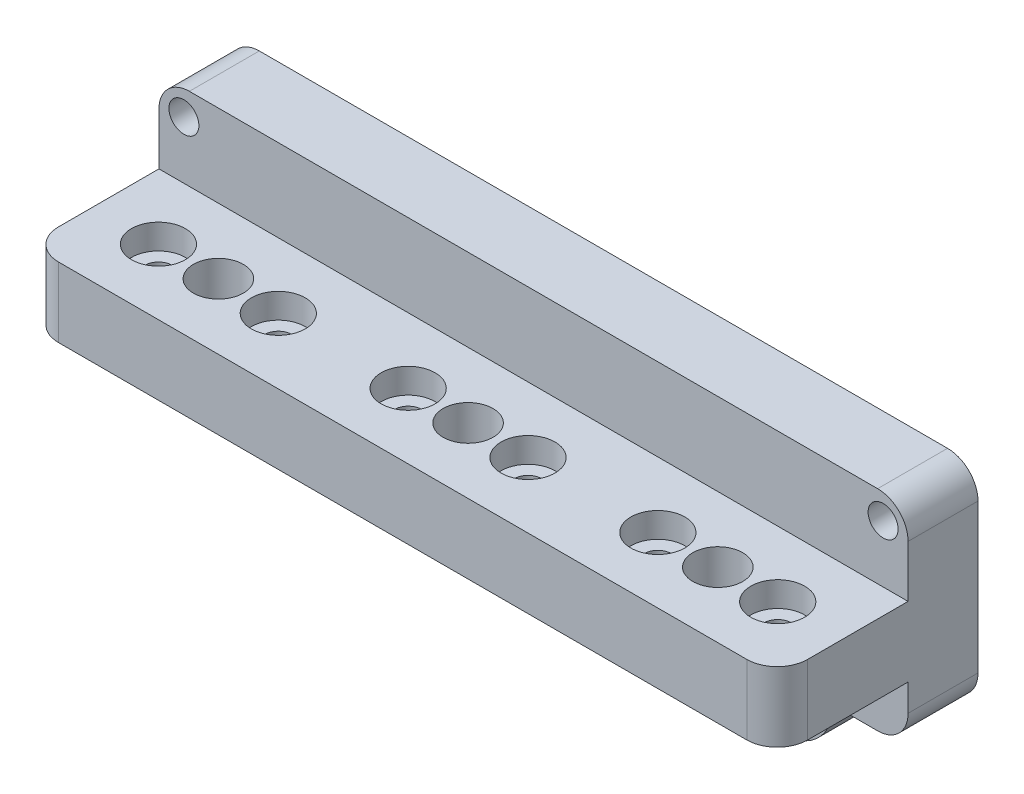
from build123d import *

# Parameters (mm, degrees)
SKETCH1_R           = 1.79994
SKETCH1_R_2         = 1.5
BOSS_EXTRUDE1_DEPTH = 7
SKETCH2_W           = 75
SKETCH2_H           = 13.099999962
SKETCH2_R           = 2.6999438
SKETCH2_R_2         = 2.499995
SKETCH2_R_3         = 1.3498449
BOSS_EXTRUDE2_DEPTH = 6.987999994
SKETCH2_3_R         = 2.6999438
SKETCH2_3_R_2       = 1.3498449
CUT_EXTRUDE1_DEPTH  = 2.5
SKETCH7_W           = 45.754771374
SKETCH7_H           = 7.378762064
SKETCH7_W_2         = 5.75825354
SKETCH7_H_2         = 4.98011117
BOSS_EXTRUDE4_DEPTH = 7
SKETCH8_W           = 15.938133918
SKETCH8_H           = 10.613167284
CUT_EXTRUDE3_DEPTH  = 21.288
FILLET3_R           = 3.048
SKETCH4_W           = 25
SKETCH4_H           = 15.064836289
CUT_EXTRUDE2_DEPTH  = 38.822


with BuildPart() as part:
    # Sketch1 → Boss-Extrude1 (new body)
    with BuildSketch(Plane.XY):
        with BuildLine():
            Line((37.5, -10.5), (30, -10.5))
            ThreePointArc((30, -10.5), (25, -15.5), (20, -10.5))
            Line((20, -10.5), (5, -10.5))
            ThreePointArc((5, -10.5), (0, -15.5), (-5, -10.5))
            Line((-5, -10.5), (-20, -10.5))
            ThreePointArc((-20, -10.5), (-25, -15.5), (-30, -10.5))
            Line((-30, -10.5), (-37.5, -10.5))
            Line((-37.5, -10.5), (-37.5, 10.5))
            Line((-37.5, 10.5), (37.5, 10.5))
            Line((37.5, 10.5), (37.5, -10.5))
        make_face()
        with Locations((-25, -10.5)):
            Circle(SKETCH1_R, mode=Mode.SUBTRACT)
        with Locations((0, -10.5)):
            Circle(SKETCH1_R, mode=Mode.SUBTRACT)
        with Locations((25, -10.5)):
            Circle(SKETCH1_R, mode=Mode.SUBTRACT)
        with Locations((-35, 8)):
            Circle(SKETCH1_R_2, mode=Mode.SUBTRACT)
        with Locations((-15, 8)):
            Circle(SKETCH1_R_2, mode=Mode.SUBTRACT)
        with Locations((-10, 8)):
            Circle(SKETCH1_R_2, mode=Mode.SUBTRACT)
        with Locations((10, 8)):
            Circle(SKETCH1_R_2, mode=Mode.SUBTRACT)
        with Locations((35, 8)):
            Circle(SKETCH1_R_2, mode=Mode.SUBTRACT)
        with Locations((15, 8)):
            Circle(SKETCH1_R_2, mode=Mode.SUBTRACT)
    extrude(amount=BOSS_EXTRUDE1_DEPTH)

    # Sketch2 → Boss-Extrude2 (add)
    with BuildSketch(Plane(origin=(0, 2.24999999, 0), x_dir=(1, 0, 0), z_dir=(0, 1, 0))):
        with Locations((0, -13.549999981)):
            Rectangle(SKETCH2_W, SKETCH2_H)
        with Locations((31.0001404, -13.549999981)):
            Circle(SKETCH2_R, mode=Mode.SUBTRACT)
        with Locations((-31.0001404, -13.549999981)):
            Circle(SKETCH2_R, mode=Mode.SUBTRACT)
        with Locations((-25, -13.549999981)):
            Circle(SKETCH2_R_2, mode=Mode.SUBTRACT)
        with Locations((-6.0001404, -13.549999981)):
            Circle(SKETCH2_R, mode=Mode.SUBTRACT)
        with Locations((6.0001404, -13.549999981)):
            Circle(SKETCH2_R, mode=Mode.SUBTRACT)
        with Locations((0, -13.549999981)):
            Circle(SKETCH2_R_2, mode=Mode.SUBTRACT)
        with Locations((-18.9998596, -13.549999981)):
            Circle(SKETCH2_R, mode=Mode.SUBTRACT)
        with Locations((25, -13.549999981)):
            Circle(SKETCH2_R_2, mode=Mode.SUBTRACT)
        with Locations((18.9998596, -13.549999981)):
            Circle(SKETCH2_R, mode=Mode.SUBTRACT)
        with Locations((-31.0001404, -13.549999981)):
            Circle(SKETCH2_R)
        with Locations((-31.0001404, -13.549999981)):
            Circle(SKETCH2_R_3, mode=Mode.SUBTRACT)
        with Locations((-18.9998596, -13.549999981)):
            Circle(SKETCH2_R)
        with Locations((-18.9998596, -13.549999981)):
            Circle(SKETCH2_R_3, mode=Mode.SUBTRACT)
        with Locations((-6.0001404, -13.549999981)):
            Circle(SKETCH2_R)
        with Locations((-6.0001404, -13.549999981)):
            Circle(SKETCH2_R_3, mode=Mode.SUBTRACT)
        with Locations((6.0001404, -13.549999981)):
            Circle(SKETCH2_R)
        with Locations((6.0001404, -13.549999981)):
            Circle(SKETCH2_R_3, mode=Mode.SUBTRACT)
        with Locations((18.9998596, -13.549999981)):
            Circle(SKETCH2_R)
        with Locations((18.9998596, -13.549999981)):
            Circle(SKETCH2_R_3, mode=Mode.SUBTRACT)
        with Locations((31.0001404, -13.549999981)):
            Circle(SKETCH2_R)
        with Locations((31.0001404, -13.549999981)):
            Circle(SKETCH2_R_3, mode=Mode.SUBTRACT)
    extrude(amount=-BOSS_EXTRUDE2_DEPTH)

    # Sketch2_3 → Cut-Extrude1 (cut)
    with BuildSketch(Plane(origin=(0, 2.24999999, 0), x_dir=(1, 0, 0), z_dir=(0, 1, 0))):
        with Locations((-31.0001404, -13.549999981)):
            Circle(SKETCH2_3_R)
        with Locations((-31.0001404, -13.549999981)):
            Circle(SKETCH2_3_R_2, mode=Mode.SUBTRACT)
        with Locations((-18.9998596, -13.549999981)):
            Circle(SKETCH2_3_R)
        with Locations((-18.9998596, -13.549999981)):
            Circle(SKETCH2_3_R_2, mode=Mode.SUBTRACT)
        with Locations((-6.0001404, -13.549999981)):
            Circle(SKETCH2_3_R)
        with Locations((-6.0001404, -13.549999981)):
            Circle(SKETCH2_3_R_2, mode=Mode.SUBTRACT)
        with Locations((6.0001404, -13.549999981)):
            Circle(SKETCH2_3_R)
        with Locations((6.0001404, -13.549999981)):
            Circle(SKETCH2_3_R_2, mode=Mode.SUBTRACT)
        with Locations((18.9998596, -13.549999981)):
            Circle(SKETCH2_3_R)
        with Locations((18.9998596, -13.549999981)):
            Circle(SKETCH2_3_R_2, mode=Mode.SUBTRACT)
        with Locations((31.0001404, -13.549999981)):
            Circle(SKETCH2_3_R)
        with Locations((31.0001404, -13.549999981)):
            Circle(SKETCH2_3_R_2, mode=Mode.SUBTRACT)
    extrude(amount=-CUT_EXTRUDE1_DEPTH, mode=Mode.SUBTRACT)

    # Sketch7 → Boss-Extrude4 (add)
    with BuildSketch(Plane(origin=(0, 0, 0), x_dir=(-1, 0, 0), z_dir=(0, 0, -1))):
        with Locations((-0.544699659, 6.810618968)):
            Rectangle(SKETCH7_W, SKETCH7_H)
        with Locations((-0.155628474, -10.184996596)):
            Rectangle(SKETCH7_W_2, SKETCH7_H_2)
    extrude(amount=-BOSS_EXTRUDE4_DEPTH)

    # Sketch8 → Cut-Extrude3 (cut)
    with BuildSketch(Plane.XY.offset(7)):
        with Locations((2.969066959, -15.806583642)):
            Rectangle(SKETCH8_W, SKETCH8_H)
    extrude(amount=-CUT_EXTRUDE3_DEPTH, mode=Mode.SUBTRACT)

    # Fillet3
    fillet3_edges = [part.edges().sort_by_distance(p)[0] for p in [
        (-37.5, 10.5, 3.5),
        (37.5, 10.5, 3.5),
        (37.5, -10.5, 3.5),
        (-37.5, -10.5, 3.5),
        (37.5, -1.244000007, 20.099999962),
        (-37.5, -1.244000007, 20.099999962),
    ]]
    fillet(fillet3_edges, radius=FILLET3_R)

    # Sketch4 → Cut-Extrude2 (cut)
    with BuildSketch(Plane.XY.offset(7)):
        with Locations((0, -12.270418149)):
            Rectangle(SKETCH4_W, SKETCH4_H)
    extrude(amount=-CUT_EXTRUDE2_DEPTH, mode=Mode.SUBTRACT)


solid = part.part
